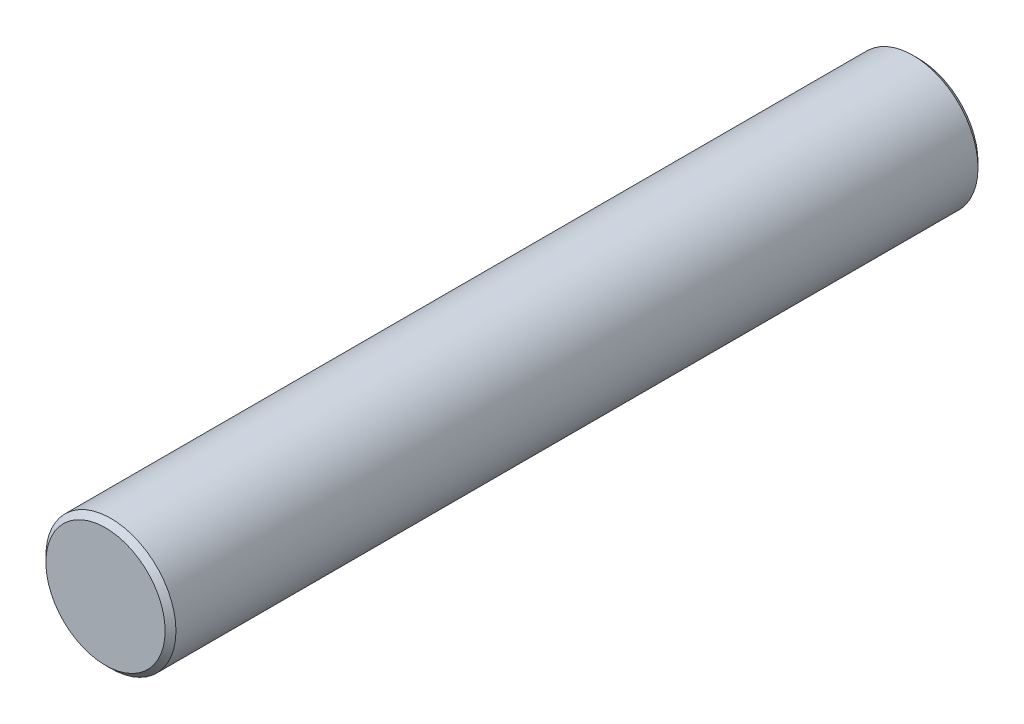
from build123d import *


with BuildPart() as part:
    # 스케치1 → 회전1 (revolve)
    with BuildSketch(Plane(origin=(0, 0, 0), x_dir=(1, 0, 0), z_dir=(0, 1, 0))):
        Polygon((5.5, 0), (0, 0), (0, -75), (5.5, -75), (6, -74.5), (6, -0.5), align=None)
    revolve(axis=Axis((0, 0, 0), (0, 0, 1)))


solid = part.part
